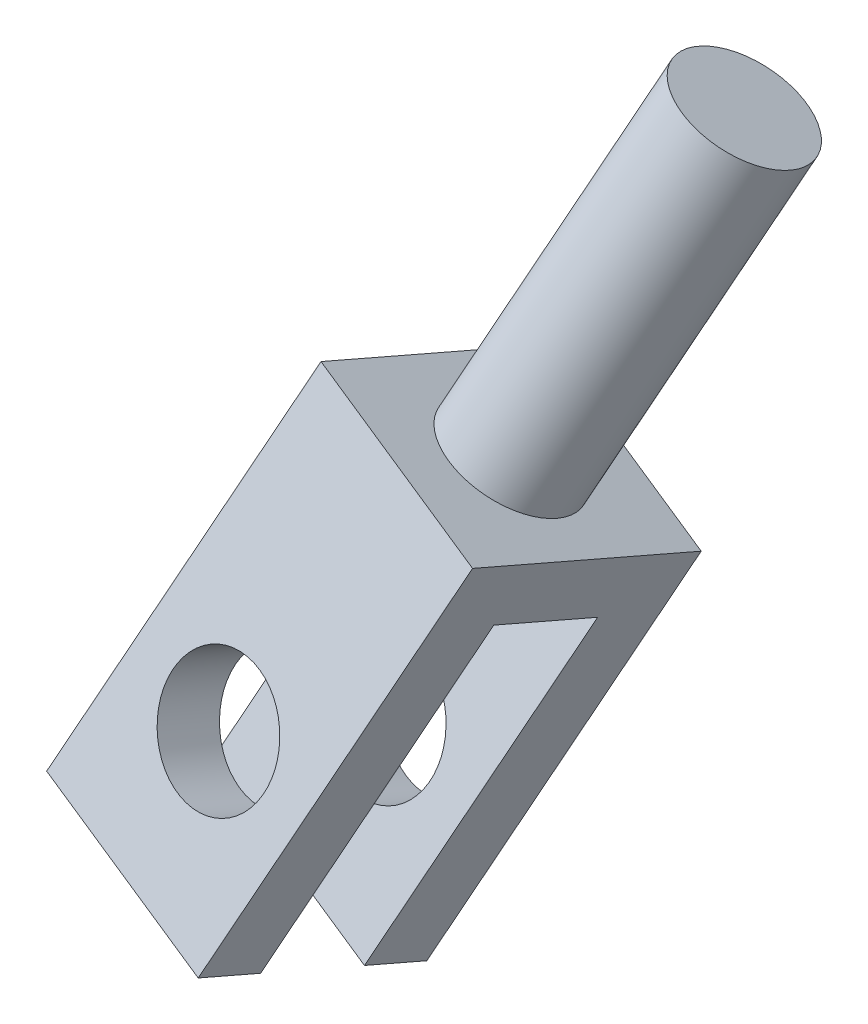
from build123d import *

# Parameters (mm, degrees)
BOSS_EXTRUDE1_DEPTH     = 10
SKETCH3_R               = 3
CUT_EXTRUDE1_DEPTH      = 17.173315528
CUT_EXTRUDE1_DEPTH_BACK = 12.173315528
SKETCH4_R               = 3
BOSS_EXTRUDE2_DEPTH     = 17


with BuildPart() as part:
    # Sketch2 → Boss-Extrude1 (new body)
    with BuildSketch(Plane(origin=(707.562217201, 137.847000427, -295.175758868), x_dir=(0.354162423, 0.881836565, -0.311341051), z_dir=(-0.931884805, 0.304841472, -0.196627535))):
        Polygon((-166.545846492, -35.496085413), (-149.545846492, -35.496085413), (-149.545846492, -40.496085413), (-166.545846492, -40.496085413), (-166.545846492, -43.496085413), (-146.545846492, -43.496085413), (-146.545846492, -32.496085413), (-166.545846492, -32.496085413), align=None)
    extrude(amount=BOSS_EXTRUDE1_DEPTH)

    # Sketch3 → Cut-Extrude1 (cut, two sides)
    with BuildSketch(Plane(origin=(18.826454002, -86.301151934, -223.021951761), x_dir=(-0.996915398, -0.028323606, -0.073194688), z_dir=(0.078483686, -0.359772079, -0.92973349))) as cut_extrude1_sk:
        with Locations((-626.324876441, 87.720012572)):
            Circle(SKETCH3_R)
    extrude(amount=CUT_EXTRUDE1_DEPTH, mode=Mode.SUBTRACT)
    extrude(cut_extrude1_sk.sketch, amount=-CUT_EXTRUDE1_DEPTH_BACK, mode=Mode.SUBTRACT)

    # Sketch4 → Boss-Extrude2 (add)
    with BuildSketch(Plane(origin=(112.448325625, 279.987482676, -98.852327665), x_dir=(0.935183927, -0.333959305, 0.117907609), z_dir=(0.354162423, 0.881836565, -0.311341051))):
        with Locations((572.690940182, 195.003128109)):
            Circle(SKETCH4_R)
    extrude(amount=BOSS_EXTRUDE2_DEPTH)


solid = part.part
